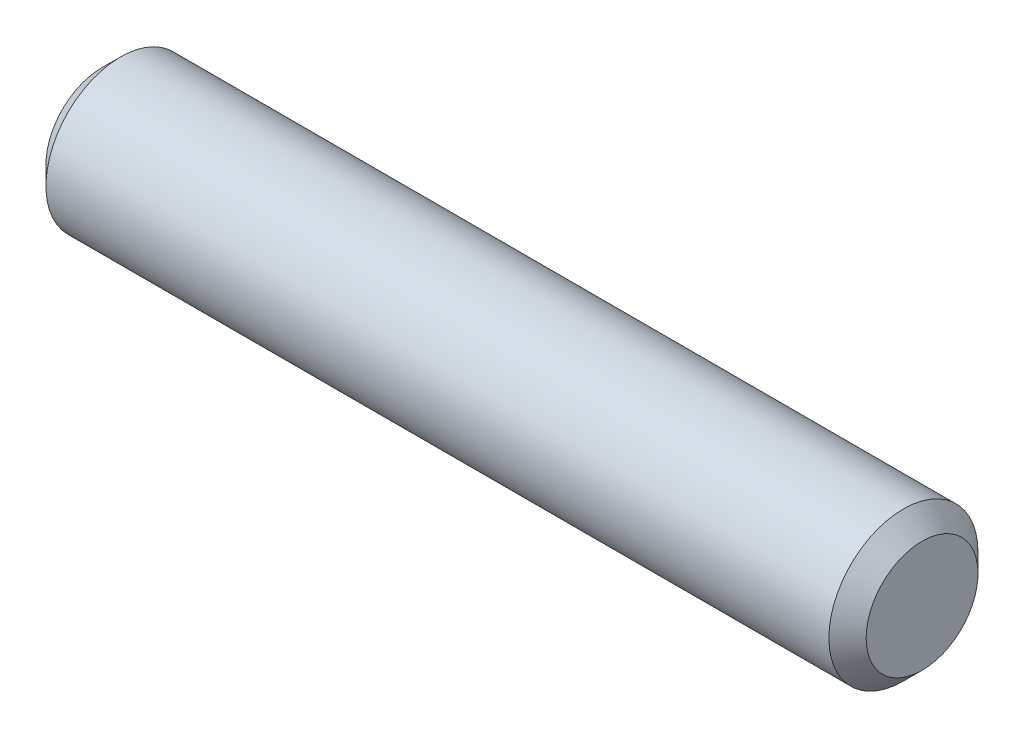
from build123d import *

# Parameters (mm, degrees)
SKETCH1_W     = 22
SKETCH1_H     = 2
CHAMFER1_SIZE = 0.5


with BuildPart() as part:
    # Sketch1 → Revolve1 (revolve)
    with BuildSketch(Plane.XY):
        with Locations((11, 1)):
            Rectangle(SKETCH1_W, SKETCH1_H)
    revolve(axis=Axis((22, 2, 0), (-1, 0, 0)))

    # Chamfer1
    chamfer1_edges = [part.edges().sort_by_distance(p)[0] for p in [
        (22, 4, 0),
        (0, 4, 0),
    ]]
    chamfer(chamfer1_edges, length=CHAMFER1_SIZE)


solid = part.part
